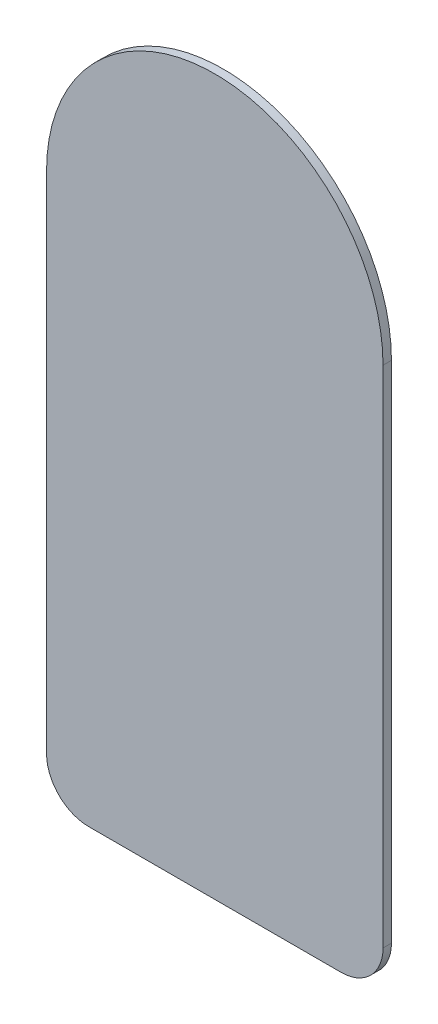
from build123d import *

# Parameters (mm, degrees)
BOSS_EXTRUDE1_DEPTH = 0.508


with BuildPart() as part:
    # Sketch1 → Boss-Extrude1 (new body)
    with BuildSketch(Plane.XY):
        with BuildLine():
            Line((10.16, -30.48), (10.16, 0))
            ThreePointArc((10.16, 0), (0, 10.16), (-10.16, 0))
            Line((-10.16, 0), (-10.16, -30.48))
            ThreePointArc((-10.16, -30.48), (-9.416051224, -32.276051224), (-7.62, -33.02))
            Line((-7.62, -33.02), (7.62, -33.02))
            ThreePointArc((7.62, -33.02), (9.416051224, -32.276051224), (10.16, -30.48))
        make_face()
    extrude(amount=BOSS_EXTRUDE1_DEPTH)


solid = part.part
